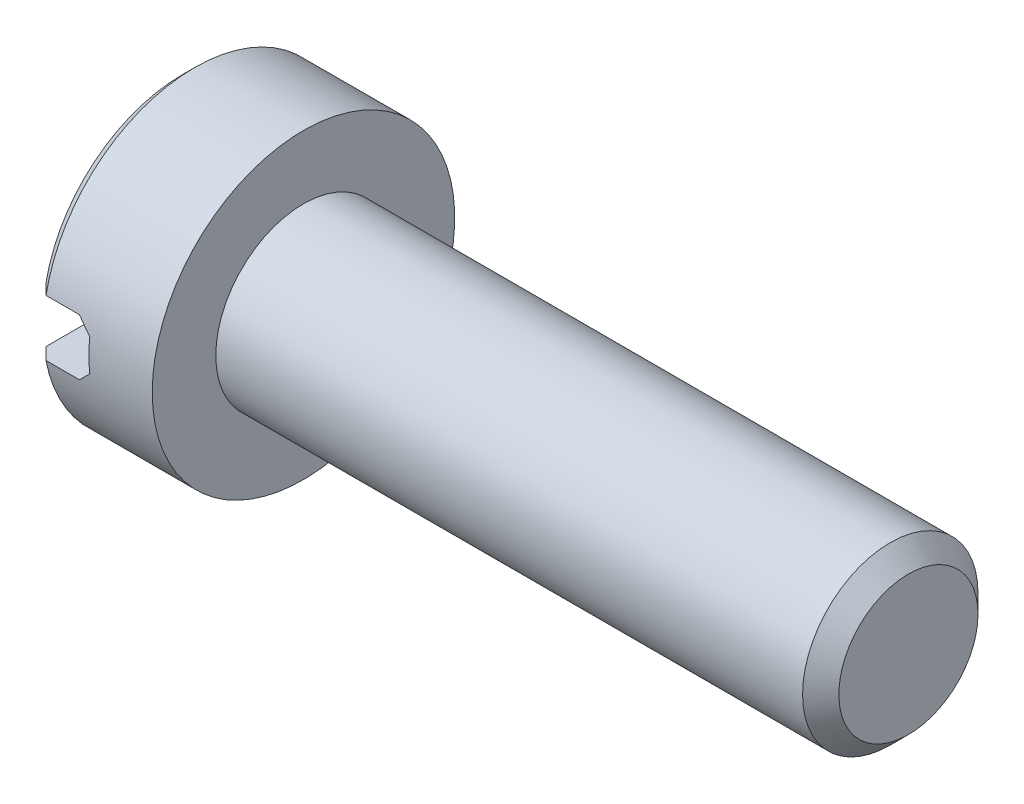
from build123d import *

# Parameters (mm, degrees)
ENL_V_MAT_EXTRU_1_DEPTH = 5
ESQUISSE3_R             = 1.45
EXTRUSION1_DEPTH        = 10
CHANFREIN1_SIZE         = 0.3


with BuildPart() as part:
    # Esquisse1 → Révolution1 (revolve)
    with BuildSketch(Plane.XY, mode=Mode.PRIVATE) as r_volution1_sk:
        Polygon((0, 0), (0, 2.3), (0.2, 2.5), (2, 2.5), (2, 0), align=None)
    revolve(r_volution1_sk.sketch.rotate(Axis((0, 0, 0), (1, 0, 0)), 90), axis=Axis((0, 0, 0), (1, 0, 0)))  # turned: the seam where the file's is

    # Esquisse2 → Enlèv. mat.-Extru.1 (cut, symmetric)
    with BuildSketch(Plane.XY):
        Polygon((0, 0.465549348), (0.753445065, 0.465549348), (0.953445065, 0.265549348), (0.953445065, -0.265549348), (0.753445065, -0.465549348), (0, -0.465549348), align=None)
    extrude(amount=ENL_V_MAT_EXTRU_1_DEPTH, both=True, mode=Mode.SUBTRACT)

    # Esquisse3 → Extrusion1 (add)
    with BuildSketch(Plane(origin=(2, 0, 0), x_dir=(0, 0, -1), z_dir=(1, 0, 0))):
        with Locations(Location((0, 0, 0), (0, 0, 180))):  # turned: the seam where the file's is
            Circle(ESQUISSE3_R)
    extrude(amount=EXTRUSION1_DEPTH)

    # Chanfrein1
    chanfrein1_edges = [part.edges().sort_by_distance(p)[0] for p in [
        (12, 0, -1.45),
    ]]
    chamfer(chanfrein1_edges, length=CHANFREIN1_SIZE)


solid = part.part
